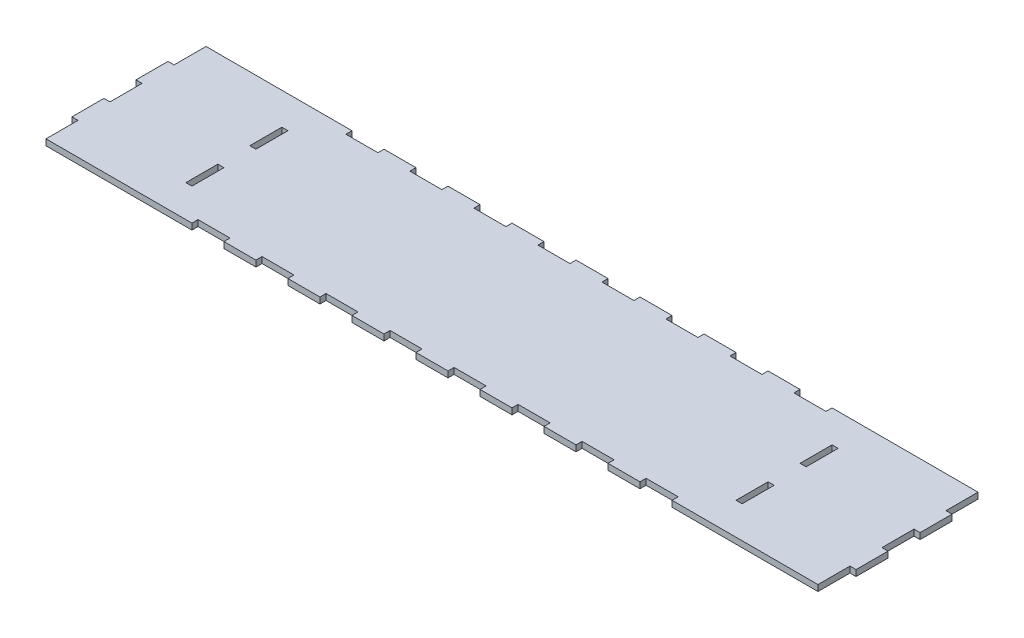
from build123d import *

# Parameters (mm, degrees)
BOSS_EXTRUDE1_DEPTH = 4.826
SKETCH2_W           = 4.826
SKETCH2_H           = 25.4
CUT_EXTRUDE1_DEPTH  = 5.826
SKETCH3_W           = 25.4
SKETCH3_H           = 4.826
CUT_EXTRUDE2_DEPTH  = 5.826


with BuildPart() as part:
    # Sketch1 → Boss-Extrude1 (new body)
    with BuildSketch(Plane(origin=(0, 0, 0), x_dir=(1, 0, 0), z_dir=(0, 1, 0))):
        Polygon((0, 101.6), (0, 127), (612.648, 127), (612.648, 101.6), (617.474, 101.6), (617.474, 76.2), (612.648, 76.2), (612.648, 50.8), (617.474, 50.8), (617.474, 25.4), (612.648, 25.4), (612.648, 0), (0, 0), (0, 25.4), (-4.826, 25.4), (-4.826, 50.8), (0, 50.8), (0, 76.2), (-4.826, 76.2), (-4.826, 101.6), align=None)
    extrude(amount=BOSS_EXTRUDE1_DEPTH)

    # Sketch2 → Cut-Extrude1 (cut, through all)
    with BuildSketch(Plane(origin=(0, 4.826, 0), x_dir=(1, 0, 0), z_dir=(0, 1, 0))):
        with Locations((524.637, 88.9)):
            Rectangle(SKETCH2_W, SKETCH2_H)
        with Locations((524.637, 38.1)):
            Rectangle(SKETCH2_W, SKETCH2_H)
        with Locations((88.011, 38.1)):
            Rectangle(SKETCH2_W, SKETCH2_H)
        with Locations((88.011, 88.9)):
            Rectangle(SKETCH2_W, SKETCH2_H)
    extrude(amount=-CUT_EXTRUDE1_DEPTH, mode=Mode.SUBTRACT)

    # Sketch3 → Cut-Extrude2 (cut, through all)
    with BuildSketch(Plane(origin=(0, 4.826, 0), x_dir=(1, 0, 0), z_dir=(0, 1, 0))):
        with Locations((484.124, 2.413)):
            Rectangle(SKETCH3_W, SKETCH3_H)
        with Locations((433.324, 2.413)):
            Rectangle(SKETCH3_W, SKETCH3_H)
        with Locations((382.524, 2.413)):
            Rectangle(SKETCH3_W, SKETCH3_H)
        with Locations((331.724, 2.413)):
            Rectangle(SKETCH3_W, SKETCH3_H)
        with Locations((280.924, 2.413)):
            Rectangle(SKETCH3_W, SKETCH3_H)
        with Locations((230.124, 2.413)):
            Rectangle(SKETCH3_W, SKETCH3_H)
        with Locations((128.524, 2.413)):
            Rectangle(SKETCH3_W, SKETCH3_H)
        with Locations((179.324, 2.413)):
            Rectangle(SKETCH3_W, SKETCH3_H)
        with Locations((128.524, 124.587)):
            Rectangle(SKETCH3_W, SKETCH3_H)
        with Locations((179.324, 124.587)):
            Rectangle(SKETCH3_W, SKETCH3_H)
        with Locations((230.124, 124.587)):
            Rectangle(SKETCH3_W, SKETCH3_H)
        with Locations((280.924, 124.587)):
            Rectangle(SKETCH3_W, SKETCH3_H)
        with Locations((331.724, 124.587)):
            Rectangle(SKETCH3_W, SKETCH3_H)
        with Locations((382.524, 124.587)):
            Rectangle(SKETCH3_W, SKETCH3_H)
        with Locations((433.324, 124.587)):
            Rectangle(SKETCH3_W, SKETCH3_H)
        with Locations((484.124, 124.587)):
            Rectangle(SKETCH3_W, SKETCH3_H)
    extrude(amount=-CUT_EXTRUDE2_DEPTH, mode=Mode.SUBTRACT)


solid = part.part
